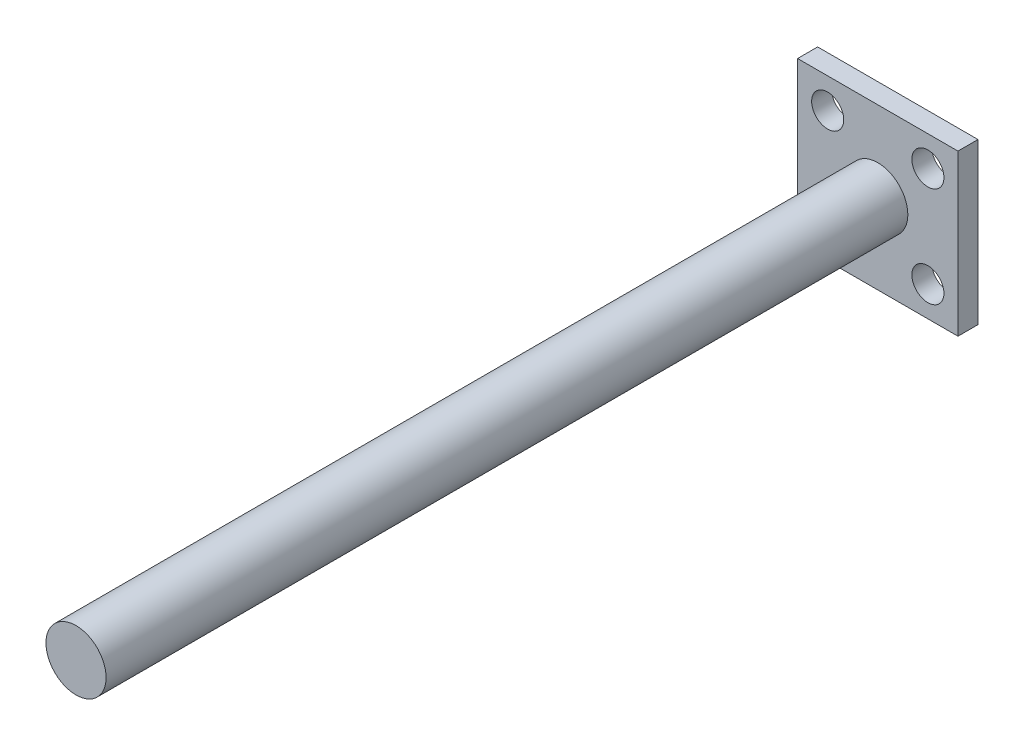
from build123d import *

# Parameters (mm, degrees)
SKETCH_1_W      = 40
SKETCH_1_H      = 40
SKETCH_1_R      = 4
EXTRUDE_1_DEPTH = 5
SKETCH_2_R      = 7.5
EXTRUDE_2_DEPTH = 200


with BuildPart() as part:
    # 草图1 → 凸台-拉伸1 (new body)
    with BuildSketch(Plane.XY):
        Rectangle(SKETCH_1_W, SKETCH_1_H)
        with Locations((-12.5, 12.5)):
            Circle(SKETCH_1_R, mode=Mode.SUBTRACT)
        with Locations((12.5, 12.5)):
            Circle(SKETCH_1_R, mode=Mode.SUBTRACT)
        with Locations((12.5, -12.5)):
            Circle(SKETCH_1_R, mode=Mode.SUBTRACT)
        with Locations((-12.5, -12.5)):
            Circle(SKETCH_1_R, mode=Mode.SUBTRACT)
    extrude(amount=EXTRUDE_1_DEPTH)

    # 草图2 → 凸台-拉伸2 (add)
    with BuildSketch(Plane.XY.offset(5)):
        Circle(SKETCH_2_R)
    extrude(amount=EXTRUDE_2_DEPTH)


solid = part.part
